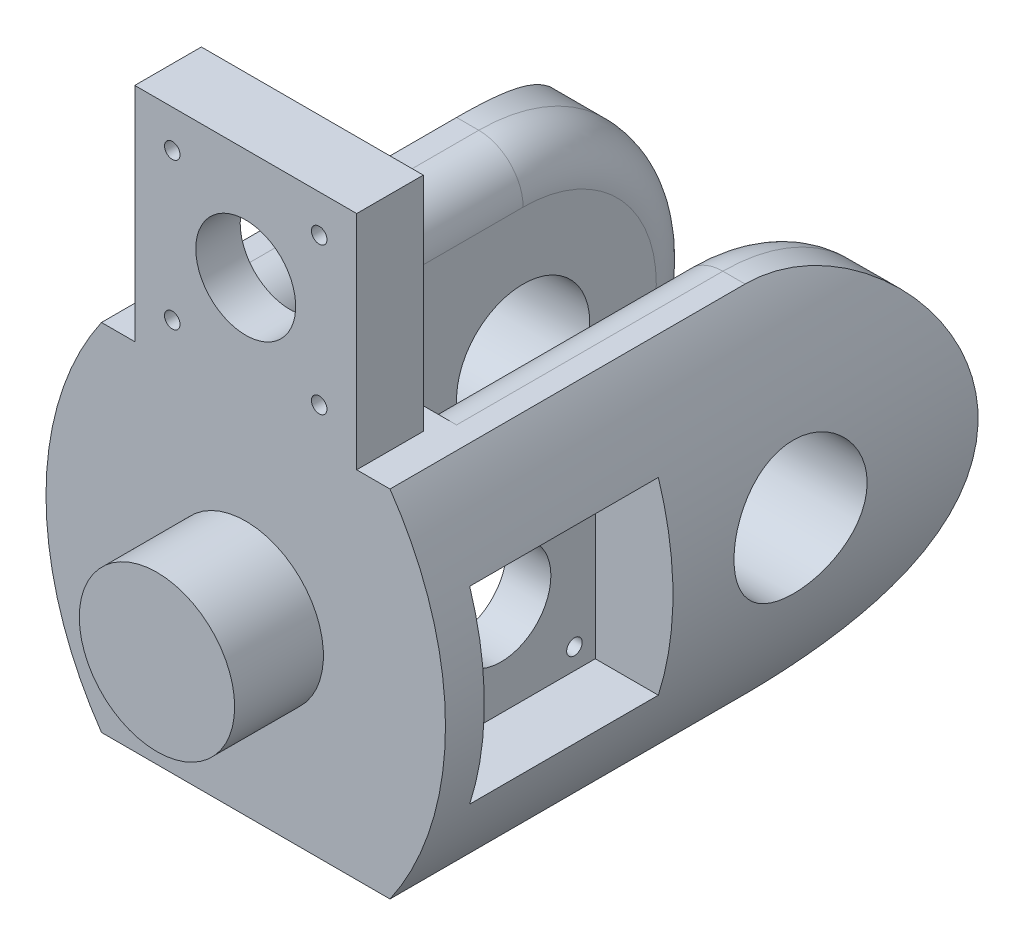
from build123d import *

# Parameters (mm, degrees)
BOSS_EXTRUDE1_DEPTH     = 100
BOSS_EXTRUDE1_2_DEPTH   = 100
BOSS_EXTRUDE2_DEPTH     = 20
SKETCH3_R               = 15
SKETCH3_R_2             = 11.25
SKETCH3_R_3             = 1.75
CUT_EXTRUDE1_DEPTH      = 46
CUT_EXTRUDE1_DEPTH_BACK = 46
SKETCH4_W               = 42.5
SKETCH4_H               = 42.5
CUT_EXTRUDE2_DEPTH      = 17.5
SKETCH5_W               = 42.5
SKETCH5_H               = 42.5
CUT_EXTRUDE4_DEPTH      = 17.5
SKETCH6_W               = 50
SKETCH6_H               = 15
BOSS_EXTRUDE3_DEPTH     = 50
SKETCH7_R               = 11.25
SKETCH7_R_2             = 1.75
CUT_EXTRUDE5_DEPTH      = 106.0000001
CUT_EXTRUDE5_DEPTH_BACK = 16.0000001
SKETCH8_W               = 42.5
SKETCH8_H               = 42.5
CUT_EXTRUDE6_DEPTH      = 5
SKETCH9_R               = 17.5
BOSS_EXTRUDE4_DEPTH     = 20
FILLET1_R               = 10
CUT_EXTRUDE7_DEPTH      = 17.5
CUT_EXTRUDE7_DEPTH_BACK = 17.5


with BuildPart() as part:
    # Sketch1 → Boss-Extrude1 (new body)
    with BuildSketch(Plane.XY):
        with BuildLine():
            Line((-17.5, -40), (-17.5, 40))
            Line((-17.5, 40), (-32.5, 40))
            ThreePointArc((-32.5, 40), (-45, 0), (-32.5, -40))
            Line((-32.5, -40), (-17.5, -40))
        make_face()
    extrude(amount=BOSS_EXTRUDE1_DEPTH)



with BuildPart() as body_2:
    # Sketch1 → Boss-Extrude1 2 (new body)
    with BuildSketch(Plane.XY):
        with BuildLine():
            Line((17.5, -40), (17.5, 40))
            Line((17.5, 40), (32.5, 40))
            ThreePointArc((32.5, 40), (45, 0), (32.5, -40))
            Line((32.5, -40), (17.5, -40))
        make_face()
    extrude(amount=BOSS_EXTRUDE1_2_DEPTH)


with BuildPart() as part_1:
    add(part.part)

    add(body_2.part)  # Boss-Extrude2 merges body 2
    # Sketch2 → Boss-Extrude2 (add)
    with BuildSketch(Plane.XY.offset(100)):
        with BuildLine():
            Line((-32.5, 40), (32.5, 40))
            ThreePointArc((32.5, 40), (45, 0), (32.5, -40))
            Line((32.5, -40), (-32.5, -40))
            ThreePointArc((-32.5, -40), (-45, 0), (-32.5, 40))
        make_face()
    extrude(amount=BOSS_EXTRUDE2_DEPTH)

    # Sketch3 → Cut-Extrude1 (cut, two sides)
    with BuildSketch(Plane(origin=(0, 0, 0), x_dir=(0, 0, -1), z_dir=(1, 0, 0))) as cut_extrude1_sk:
        with BuildLine():
            ThreePointArc((-40, 40), (-11.715728753, 28.284271247), (0, 0))
            Line((0, 0), (0, 40))
            Line((0, 40), (-40, 40))
        make_face()
        with BuildLine():
            Line((0, -40), (0, 0))
            ThreePointArc((0, 0), (-11.715728753, -28.284271247), (-40, -40))
            Line((-40, -40), (0, -40))
        make_face()
        with Locations((-40, 0)):
            Circle(SKETCH3_R)
        with Locations((-90, 0)):
            Circle(SKETCH3_R_2)
        with Locations((-73.45, -16.55)):
            Circle(SKETCH3_R_3)
        with Locations((-73.45, 16.55)):
            Circle(SKETCH3_R_3)
        with Locations((-106.55, 16.55)):
            Circle(SKETCH3_R_3)
        with Locations((-106.55, -16.55)):
            Circle(SKETCH3_R_3)
    extrude(amount=CUT_EXTRUDE1_DEPTH, mode=Mode.SUBTRACT)
    extrude(cut_extrude1_sk.sketch, amount=-CUT_EXTRUDE1_DEPTH_BACK, mode=Mode.SUBTRACT)

    # Sketch4 → Cut-Extrude2 (cut)
    with BuildSketch(Plane(origin=(45, 0, 0), x_dir=(0, 0, -1), z_dir=(1, 0, 0))):
        with Locations((-90, 0)):
            Rectangle(SKETCH4_W, SKETCH4_H)
    extrude(amount=-CUT_EXTRUDE2_DEPTH, mode=Mode.SUBTRACT)

    # Sketch5 → Cut-Extrude4 (cut)
    with BuildSketch(Plane(origin=(-45, 0, 0), x_dir=(0, 0, -1), z_dir=(1, 0, 0))):
        with Locations((-90, 0)):
            Rectangle(SKETCH5_W, SKETCH5_H)
    extrude(amount=CUT_EXTRUDE4_DEPTH, mode=Mode.SUBTRACT)

    # Sketch6 → Boss-Extrude3 (add)
    with BuildSketch(Plane(origin=(0, 40, 0), x_dir=(1, 0, 0), z_dir=(0, 1, 0))):
        with Locations((0, -112.5)):
            Rectangle(SKETCH6_W, SKETCH6_H)
    extrude(amount=BOSS_EXTRUDE3_DEPTH)

    # Sketch7 → Cut-Extrude5 (cut, two sides)
    with BuildSketch(Plane(origin=(0, 0, 105), x_dir=(-1, 0, 0), z_dir=(0, 0, -1))) as cut_extrude5_sk:
        with Locations((0, 65)):
            Circle(SKETCH7_R)
        with Locations((16.55, 81.55)):
            Circle(SKETCH7_R_2)
        with Locations((-16.55, 81.55)):
            Circle(SKETCH7_R_2)
        with Locations((-16.55, 48.45)):
            Circle(SKETCH7_R_2)
        with Locations((16.55, 48.45)):
            Circle(SKETCH7_R_2)
    extrude(amount=CUT_EXTRUDE5_DEPTH, mode=Mode.SUBTRACT)
    extrude(cut_extrude5_sk.sketch, amount=-CUT_EXTRUDE5_DEPTH_BACK, mode=Mode.SUBTRACT)

    # Sketch8 → Cut-Extrude6 (cut)
    with BuildSketch(Plane(origin=(0, 0, 105), x_dir=(-1, 0, 0), z_dir=(0, 0, -1))):
        with Locations((0, 65)):
            Rectangle(SKETCH8_W, SKETCH8_H)
    extrude(amount=-CUT_EXTRUDE6_DEPTH, mode=Mode.SUBTRACT)

    # Sketch9 → Boss-Extrude4 (add)
    with BuildSketch(Plane.XY.offset(120)):
        Circle(SKETCH9_R)
    extrude(amount=BOSS_EXTRUDE4_DEPTH)

    # Fillet1
    fillet1_edges = [part_1.edges().sort_by_distance(p)[0] for p in [
        (17.5, 40, 70),
        (17.5, -40, 70),
        (-17.5, 0, 0),
        (17.5, 0, 0),
        (-17.5, 40, 70),
        (-17.5, -40, 70),
    ]]
    fillet(fillet1_edges, radius=FILLET1_R)

    # Sketch10 → Cut-Extrude7 (cut, two sides)
    with BuildSketch(Plane(origin=(0, 0, 0), x_dir=(0, 0, -1), z_dir=(1, 0, 0))) as cut_extrude7_sk:
        with BuildLine():
            Line((-106.55, 20.3), (-92.703309556, 20.3))
            Line((-92.703309556, 20.3), (-92.703309556, 12.8))
            Line((-92.703309556, 12.8), (-106.55, 12.8))
            ThreePointArc((-106.55, 12.8), (-110.3, 16.55), (-106.55, 20.3))
        make_face()
        with BuildLine():
            Line((-106.55, -12.8), (-92.703309556, -12.8))
            Line((-92.703309556, -12.8), (-92.703309556, -20.3))
            Line((-92.703309556, -20.3), (-106.55, -20.3))
            ThreePointArc((-106.55, -20.3), (-110.3, -16.55), (-106.55, -12.8))
        make_face()
    extrude(amount=CUT_EXTRUDE7_DEPTH, mode=Mode.SUBTRACT)
    extrude(cut_extrude7_sk.sketch, amount=-CUT_EXTRUDE7_DEPTH_BACK, mode=Mode.SUBTRACT)


solid = part_1.part
